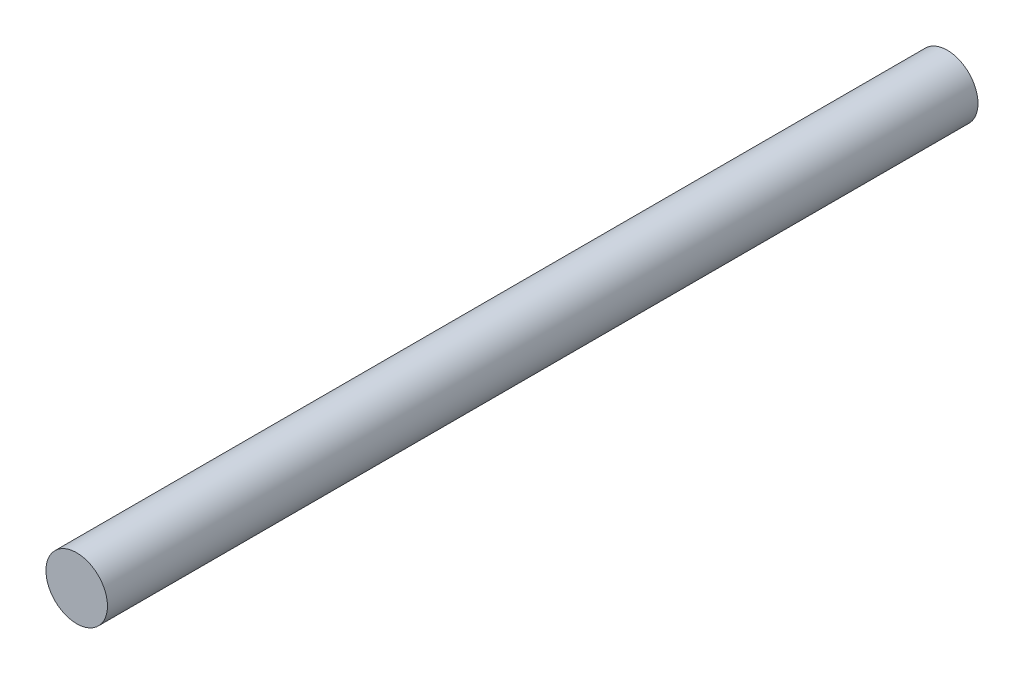
from build123d import *

# Parameters (mm, degrees)
SKETCH2_R           = 15.9
BOSS_EXTRUDE1_DEPTH = 450


with BuildPart() as part:
    # Sketch2 → Boss-Extrude1 (new body)
    with BuildSketch(Plane.XY):
        Circle(SKETCH2_R)
    extrude(amount=BOSS_EXTRUDE1_DEPTH)


solid = part.part
